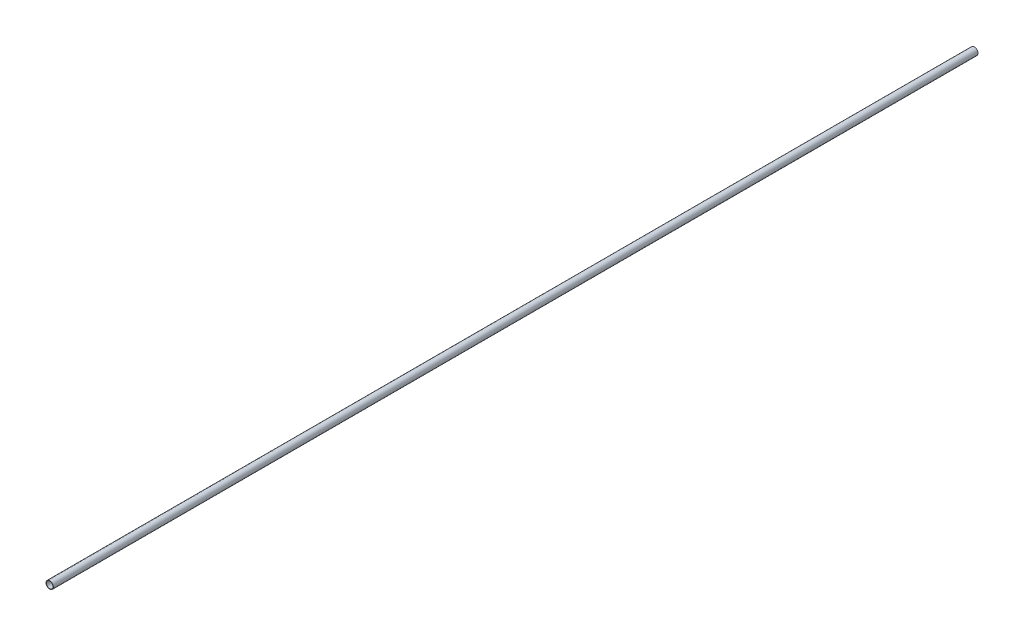
from build123d import *

# Parameters (mm, degrees)
SKETCH_1_R      = 8
SKETCH_1_R_2    = 7
EXTRUDE_1_DEPTH = 1000


with BuildPart() as part:
    # Эскиз1 → Бобышка-Вытянуть1 (new body, symmetric)
    with BuildSketch(Plane.XY):
        Circle(SKETCH_1_R)
        Circle(SKETCH_1_R_2, mode=Mode.SUBTRACT)
    extrude(amount=EXTRUDE_1_DEPTH, both=True)


solid = part.part
